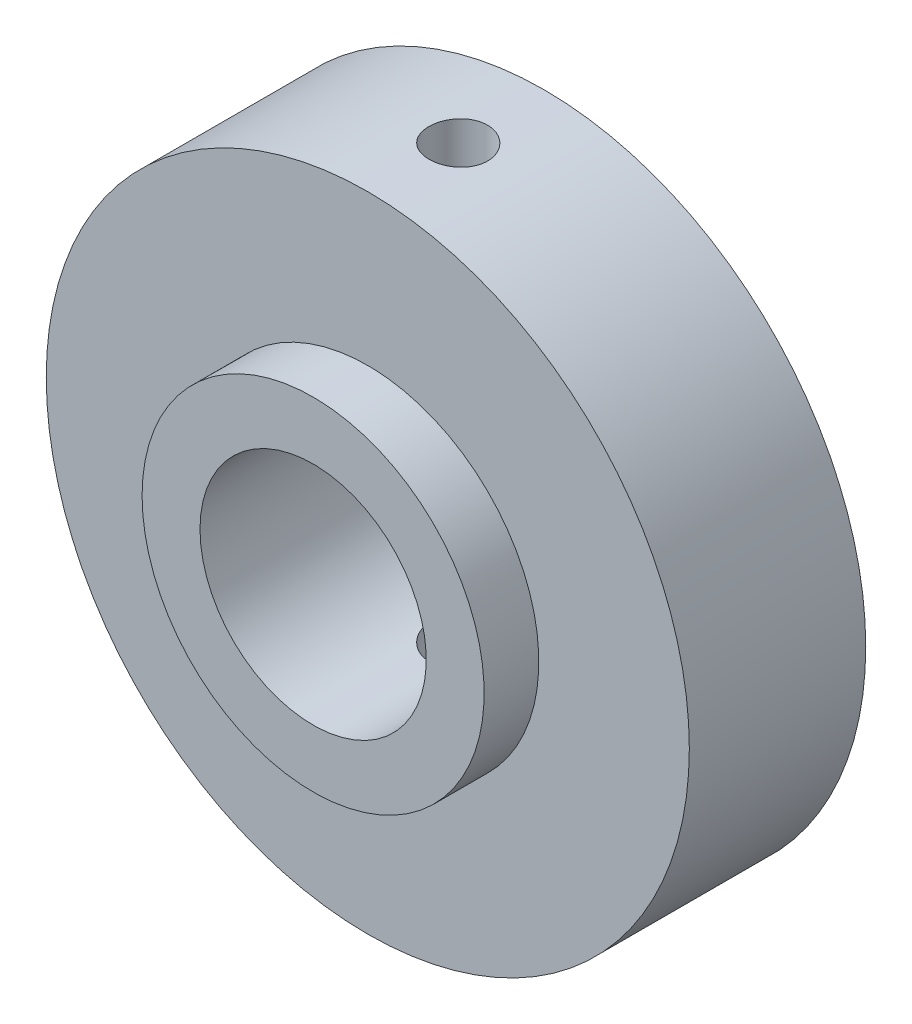
from build123d import *

# Parameters (mm, degrees)
SKETCH1_W          = 2.15
SKETCH1_H          = 2.03
SKETCH2_R          = 1.0922
CUT_EXTRUDE1_DEPTH = 24.876


with BuildPart() as part:
    # Sketch1 → Revolve1 (revolve)
    with BuildSketch(Plane(origin=(0, 0, 0), x_dir=(1, 0, 0), z_dir=(0, 1, 0))):
        with Locations((-2.995601826, -13.170436757)):
            Rectangle(SKETCH1_W, SKETCH1_H)
        Polygon((-4.070601826, -12.155436757), (-1.920601826, -12.155436757), (-1.920601826, -3.573436757), (-4.070601826, -3.573436757), (-4.070601826, -5.605436757), align=None)
        Polygon((-5.107903637, -12.155436757), (-4.070601826, -12.155436757), (-4.070601826, -5.605436757), (-9.658601826, -5.605436757), (-9.658601826, -12.155436757), align=None)
    revolve(axis=Axis((2.279398174, 0, -19.129935757), (0, 0, 1)))

    # Sketch2 → Cut-Extrude1 (cut, through all)
    with BuildSketch(Plane(origin=(0, 11.938, 0), x_dir=(1, 0, 0), z_dir=(0, 1, 0))):
        with Locations((2.369164509, -8.88650333)):
            Circle(SKETCH2_R)
    extrude(amount=-CUT_EXTRUDE1_DEPTH, mode=Mode.SUBTRACT)


solid = part.part
